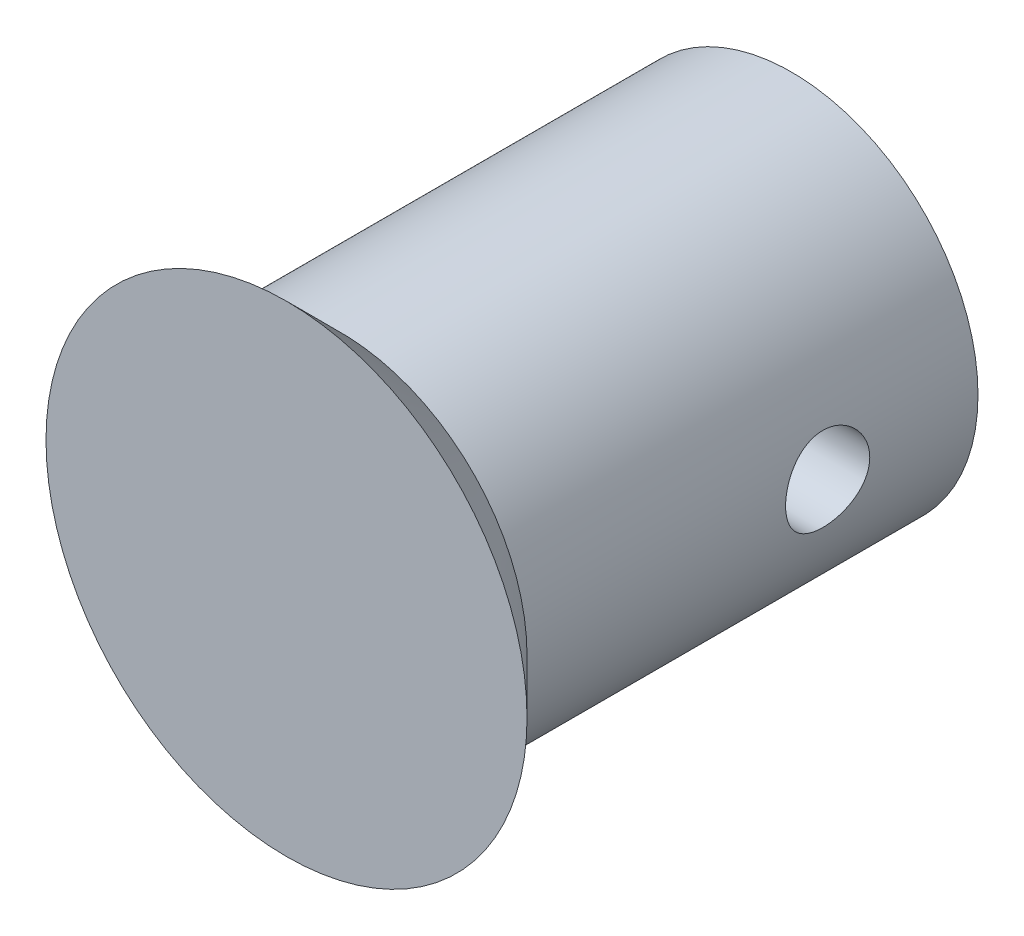
from build123d import *

# Parameters (mm, degrees)
SKETCH_2_R               = 1.75
CUT_EXTRUDE_1_DEPTH      = 11
CUT_EXTRUDE_1_DEPTH_BACK = 11


with BuildPart() as part:
    # Эскиз1 → Повернуть1 (revolve)
    with BuildSketch(Plane(origin=(0, 0, 0), x_dir=(0, 0, -1), z_dir=(1, 0, 0))):
        Polygon((0, 0), (0, 10), (2.25, 7.75), (21, 7.75), (21, 0), align=None)
    revolve(axis=Axis((0, 0, 1000), (0, 0, -1)))

    # Эскиз2 → Вырез-Вытянуть1 (cut, two sides)
    with BuildSketch(Plane(origin=(0, 0, 0), x_dir=(0, 0, -1), z_dir=(1, 0, 0))) as cut_extrude_1_sk:
        with Locations((14.75, 0)):
            Circle(SKETCH_2_R)
    extrude(amount=CUT_EXTRUDE_1_DEPTH, mode=Mode.SUBTRACT)
    extrude(cut_extrude_1_sk.sketch, amount=-CUT_EXTRUDE_1_DEPTH_BACK, mode=Mode.SUBTRACT)


solid = part.part
